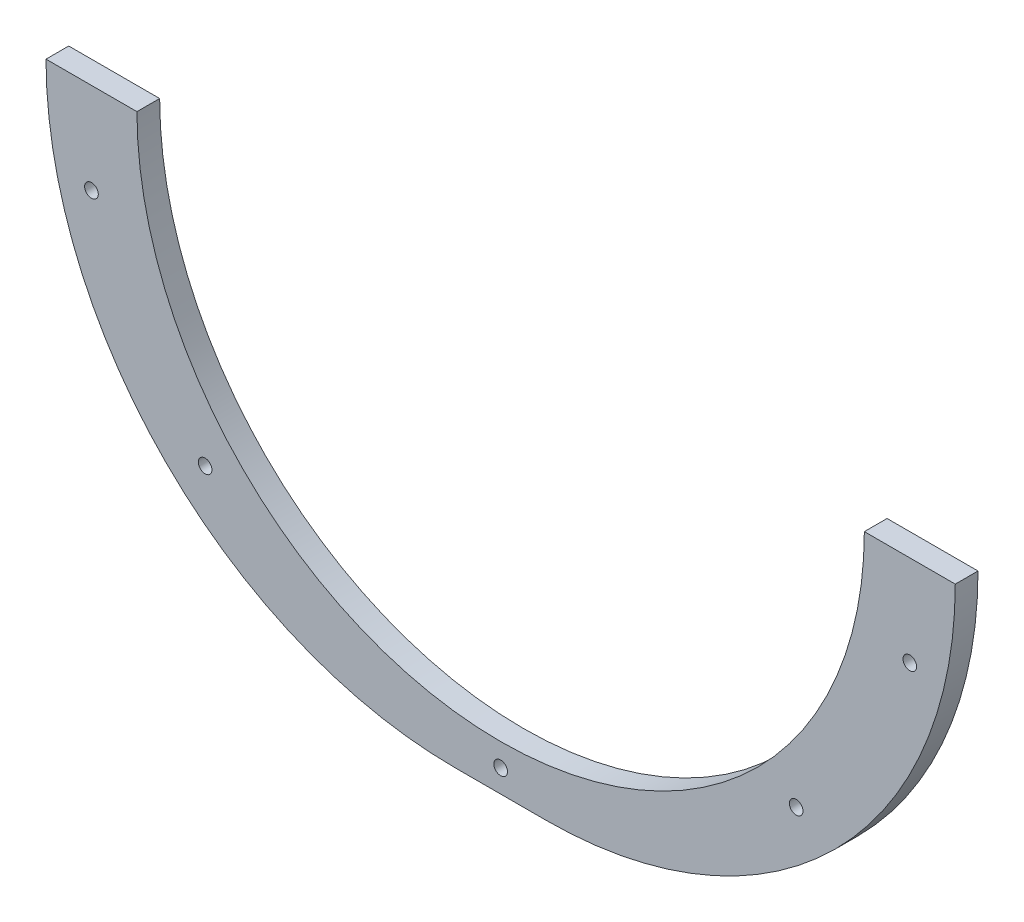
from build123d import *

# Parameters (mm, degrees)
RESSALTO_EXTRUS_O1_DEPTH = 5
ESBO_O2_R                = 1.5
CORTE_EXTRUS_O1_DEPTH    = 10


with BuildPart() as part:
    # Esboço1 → Ressalto-extrusão1 (new body)
    with BuildSketch(Plane.XY):
        with BuildLine():
            Line((-16.520541228, -40.769230769), (3.479458772, -40.769230769))
            ThreePointArc((3.479458772, -40.769230769), (83.479458772, -120.769230769), (163.479458772, -40.769230769))
            Line((163.479458772, -40.769230769), (183.479458772, -40.769230769))
            ThreePointArc((183.479458772, -40.769230769), (157.119069078, -104.408841076), (93.479458772, -130.769230769))
            Line((93.479458772, -130.769230769), (73.479458772, -130.769230769))
            ThreePointArc((73.479458772, -130.769230769), (9.839848465, -104.408841076), (-16.520541228, -40.769230769))
        make_face()
    extrude(amount=RESSALTO_EXTRUS_O1_DEPTH)

    # Esboço2 → Corte-extrusão1 (cut)
    with BuildSketch(Plane.XY.offset(5)):
        with Locations((83.479458772, -125.769230769)):
            Circle(ESBO_O2_R)
        with Locations((148.479458772, -100.769230769)):
            Circle(ESBO_O2_R)
        with Locations((173.479458772, -60.769230769)):
            Circle(ESBO_O2_R)
        with Locations((-6.520541228, -60.769230769)):
            Circle(ESBO_O2_R)
        with Locations((18.479458772, -100.769230769)):
            Circle(ESBO_O2_R)
    extrude(amount=-CORTE_EXTRUS_O1_DEPTH, mode=Mode.SUBTRACT)


solid = part.part
